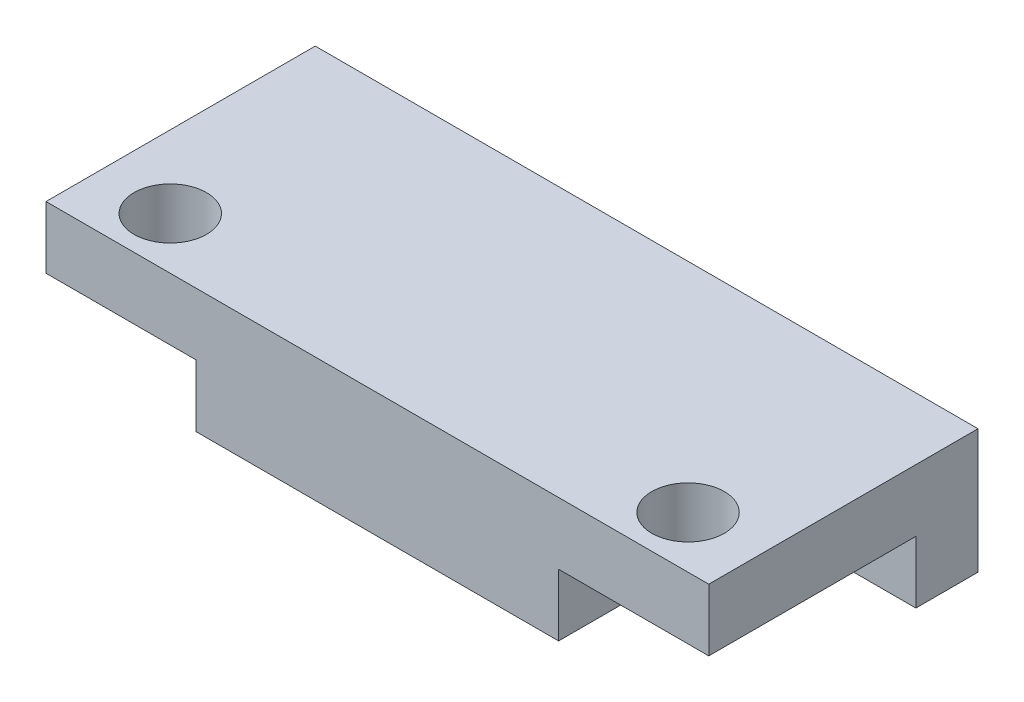
from build123d import *

# Parameters (mm, degrees)
SKETCH_1_W          = 32
SKETCH_1_H          = 13
EXTRUDE_1_DEPTH     = 3
SKETCH_2_R          = 1.75
CUT_EXTRUDE_1_DEPTH = 4
EXTRUDE_2_DEPTH     = 3


with BuildPart() as part:
    # 스케치1 → 보스-돌출1 (new body)
    with BuildSketch(Plane(origin=(0, 0, 0), x_dir=(1, 0, 0), z_dir=(0, 1, 0))):
        Rectangle(SKETCH_1_W, SKETCH_1_H)
    extrude(amount=EXTRUDE_1_DEPTH)

    # 스케치2 → 컷-돌출1 (cut, through all)
    with BuildSketch(Plane(origin=(0, 3, 0), x_dir=(1, 0, 0), z_dir=(0, 1, 0))):
        with Locations((-12.5, -4)):
            Circle(SKETCH_2_R)
        with Locations((12.5, -4)):
            Circle(SKETCH_2_R)
    extrude(amount=-CUT_EXTRUDE_1_DEPTH, mode=Mode.SUBTRACT)

    # 스케치3 → 보스-돌출2 (add)
    with BuildSketch(Plane.XZ):
        Polygon((-8.75, 6.5), (8.75, 6.5), (8.75, -3.5), (16, -3.5), (16, -6.5), (-16, -6.5), (-16, -3.5), (-8.75, -3.5), align=None)
    extrude(amount=EXTRUDE_2_DEPTH)


solid = part.part
